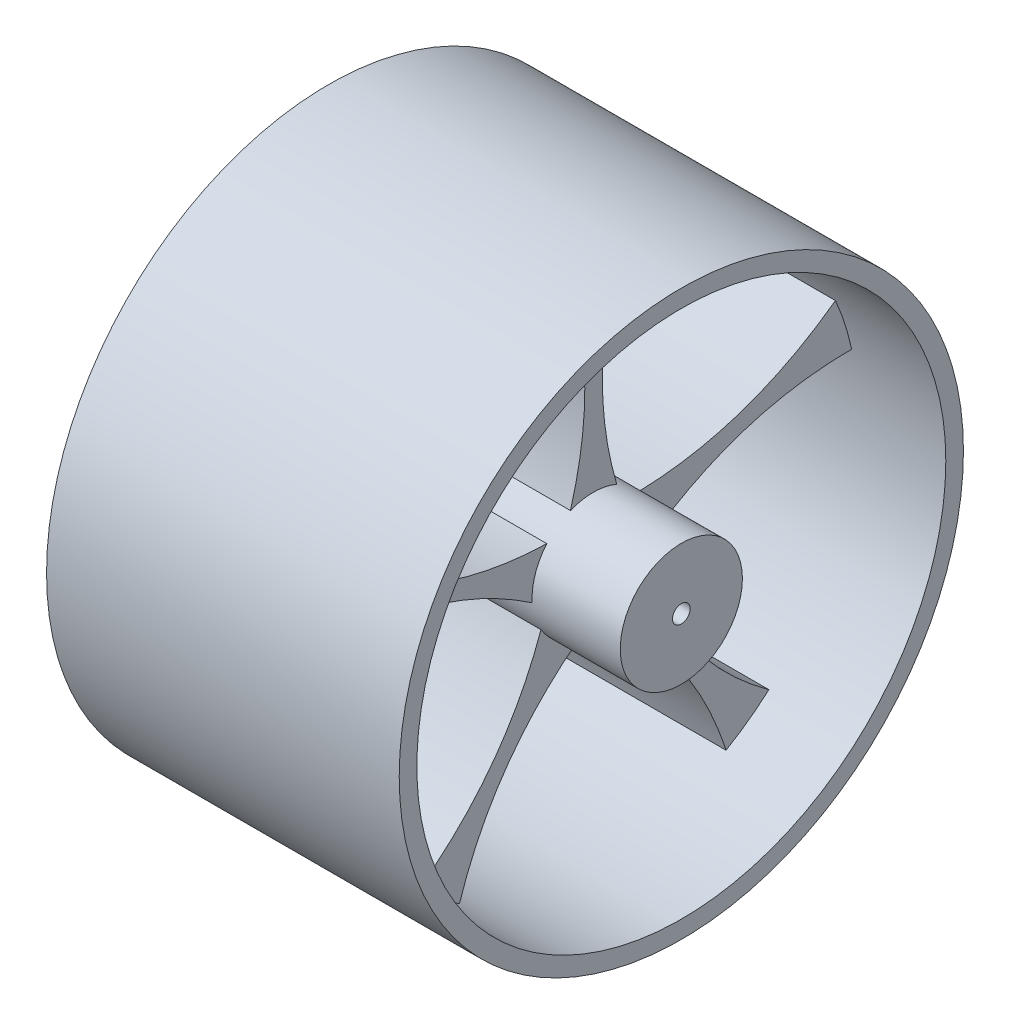
from build123d import *

# Parameters (mm, degrees)
SKETCH1_R           = 80
SKETCH1_R_2         = 75
SKETCH1_R_3         = 15
SKETCH1_R_4         = 17.320508076
BOSS_EXTRUDE1_DEPTH = 100
BOSS_EXTRUDE2_START = -25
BOSS_EXTRUDE2_DEPTH = 50
SKETCH6_R           = 2.5
CUT_EXTRUDE1_DEPTH  = 100
CIRPATTERN1_COUNT   = 5


with BuildPart() as part:
    # Sketch1 → Boss-Extrude1 (new body)
    with BuildSketch(Plane(origin=(0, 0, 0), x_dir=(0, 0, -1), z_dir=(1, 0, 0))):
        Circle(SKETCH1_R)
        Circle(SKETCH1_R_2, mode=Mode.SUBTRACT)
        Circle(SKETCH1_R_3)
        Polygon((-17.320508076, 0), (-8.660254038, -15), (8.660254038, -15), (17.320508076, 0), (8.660254038, 15), (-8.660254038, 15), align=None)
        Circle(SKETCH1_R_4)
    extrude(amount=BOSS_EXTRUDE1_DEPTH)

    # Sketch7 → Boss-Extrude2 (add)
    with BuildSketch(Plane.ZY.offset(BOSS_EXTRUDE2_START)):
        with BuildLine():
            add(Edge.make_bspline(
                [(6.440327224, 16.078625105), (2.594720076, 29.237330687), (2.383712029, 42.366824241)],
                knots=[0.048824519, 0.048824519, 0.048824519, 0.47524405, 0.47524405, 0.47524405], degree=2))
            add(Edge.make_bspline(
                [(2.383712029, 42.366824241), (2.359211722, 43.891299831), (2.383712029, 45.415381593)],
                knots=[0.47524405, 0.47524405, 0.47524405, 0.52475595, 0.52475595, 0.52475595], degree=2))
            add(Edge.make_bspline(
                [(2.383712029, 45.415381593), (2.618880242, 60.044406046), (7.368611427, 74.637146017)],
                knots=[0.52475595, 0.52475595, 0.52475595, 1, 1, 1], degree=2))
            ThreePointArc((7.368611427, 74.637146017), (-0.131481233, 74.999884751), (-7.630255972, 74.610851716))
            add(Edge.make_bspline(
                [(-6.683078321, 15.979251051), (1.926800998, 45.372338084), (-7.630255972, 74.610851716)],
                knots=[0.049553835, 0.049553835, 0.049553835, 1, 1, 1], degree=2))
            ThreePointArc((-6.683078321, 15.979251051), (-4.684644195, 16.674954536), (-2.616287971, 17.121770856))
            ThreePointArc((-2.616287971, 17.121770856), (-0.117518624, 17.320109393), (2.383712029, 17.155696342))
            ThreePointArc((2.383712029, 17.155696342), (4.444765212, 16.740491695), (6.440327224, 16.078625105))
        make_face()
    boss_extrude2 = extrude(amount=-BOSS_EXTRUDE2_DEPTH)

    # Sketch6 → Cut-Extrude1 (cut)
    with BuildSketch(Plane.ZY):
        Circle(SKETCH6_R)
    extrude(amount=-CUT_EXTRUDE1_DEPTH, mode=Mode.SUBTRACT)

    # CirPattern1: Boss-Extrude2 ×5 about axis
    cirpattern1_axis = Axis((100, 0, 0), (-1, 0, 0))
    for i in range(1, CIRPATTERN1_COUNT):
        add(boss_extrude2.rotate(cirpattern1_axis, i * 360 / CIRPATTERN1_COUNT))


solid = part.part
